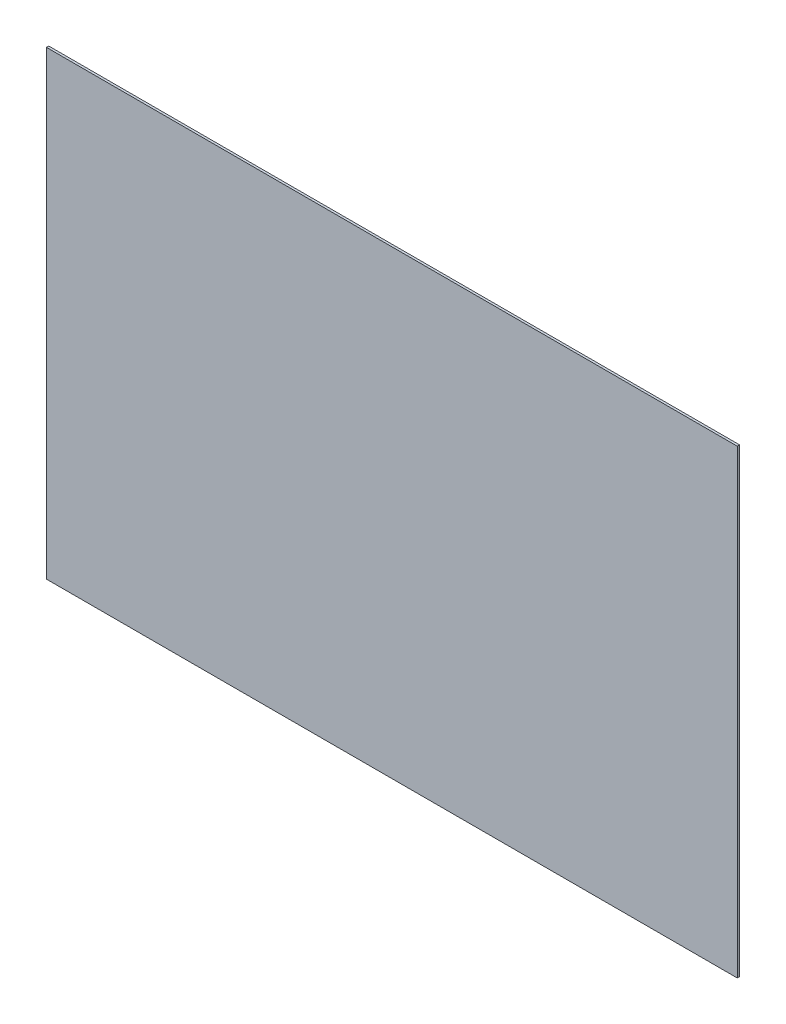
from build123d import *

# Parameters (mm, degrees)
SKETCH1_W           = 300
SKETCH1_H           = 200
BOSS_EXTRUDE1_DEPTH = 1


with BuildPart() as part:
    # Sketch1 → Boss-Extrude1 (new body)
    with BuildSketch(Plane.XY):
        with Locations((198.503381024, 218.417277588)):
            Rectangle(SKETCH1_W, SKETCH1_H)
    extrude(amount=BOSS_EXTRUDE1_DEPTH)


solid = part.part
